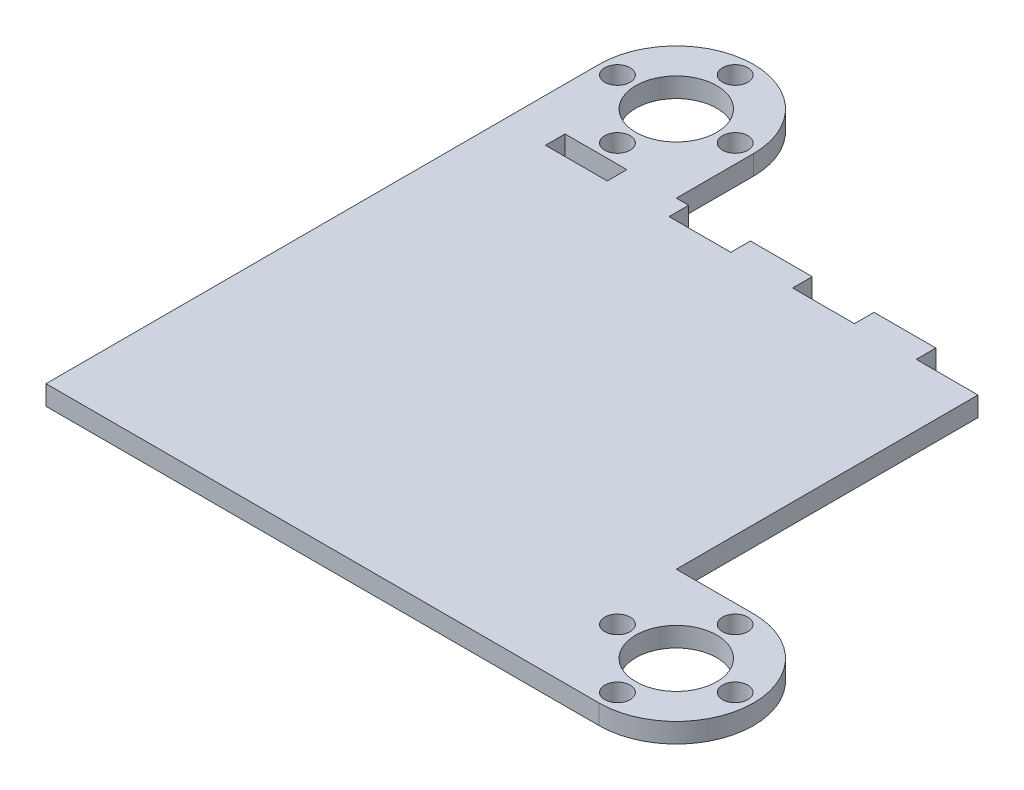
from build123d import *

# Parameters (mm, degrees)
SKETCH1_R           = 2.05
SKETCH1_R_2         = 6.55
BOSS_EXTRUDE1_DEPTH = 3.175
SKETCH2_W           = 10
SKETCH2_H           = 3.175
CUT_EXTRUDE1_DEPTH  = 3.175


with BuildPart() as part:
    # Sketch1 → Boss-Extrude1 (new body)
    with BuildSketch(Plane(origin=(0, 0, 0), x_dir=(1, 0, 0), z_dir=(0, 1, 0))):
        with BuildLine():
            ThreePointArc((-13.5, 51), (-26, 63.5), (-38.5, 51))
            Line((-38.5, 51), (-38.5, 38.5))
            Line((-38.5, 38.5), (-38.5, -38.5))
            Line((-38.5, -38.5), (38.5, -38.5))
            Line((38.5, -38.5), (51, -38.5))
            ThreePointArc((51, -38.5), (63.5, -26), (51, -13.5))
            Line((51, -13.5), (38.5, -13.5))
            Line((38.5, -13.5), (38.5, 38.5))
            Line((38.5, 38.5), (-13.5, 38.5))
            Line((-13.5, 38.5), (-13.5, 51))
        make_face()
        with Locations((41.475, -26)):
            Circle(SKETCH1_R, mode=Mode.SUBTRACT)
        with Locations((51, -35.525)):
            Circle(SKETCH1_R, mode=Mode.SUBTRACT)
        with Locations((51, -26)):
            Circle(SKETCH1_R_2, mode=Mode.SUBTRACT)
        with Locations((60.525, -26)):
            Circle(SKETCH1_R, mode=Mode.SUBTRACT)
        with Locations((-35.525, 51)):
            Circle(SKETCH1_R, mode=Mode.SUBTRACT)
        with Locations((-26, 41.475)):
            Circle(SKETCH1_R, mode=Mode.SUBTRACT)
        with Locations((-26, 51)):
            Circle(SKETCH1_R_2, mode=Mode.SUBTRACT)
        with Locations((-16.475, 51)):
            Circle(SKETCH1_R, mode=Mode.SUBTRACT)
        with Locations((-26, 60.525)):
            Circle(SKETCH1_R, mode=Mode.SUBTRACT)
        with Locations((51, -16.475)):
            Circle(SKETCH1_R, mode=Mode.SUBTRACT)
    extrude(amount=BOSS_EXTRUDE1_DEPTH)

    # Sketch2 → Cut-Extrude1 (cut)
    with BuildSketch(Plane(origin=(0, 3.175, 0), x_dir=(1, 0, 0), z_dir=(0, 1, 0))):
        with Locations((33.5, 36.9125)):
            Rectangle(SKETCH2_W, SKETCH2_H)
        with Locations((13.5, 36.9125)):
            Rectangle(SKETCH2_W, SKETCH2_H)
        with Locations((-6.5, 36.9125)):
            Rectangle(SKETCH2_W, SKETCH2_H)
        with Locations((-26.5, 36.9125)):
            Rectangle(SKETCH2_W, SKETCH2_H)
    extrude(amount=-CUT_EXTRUDE1_DEPTH, mode=Mode.SUBTRACT)


solid = part.part
